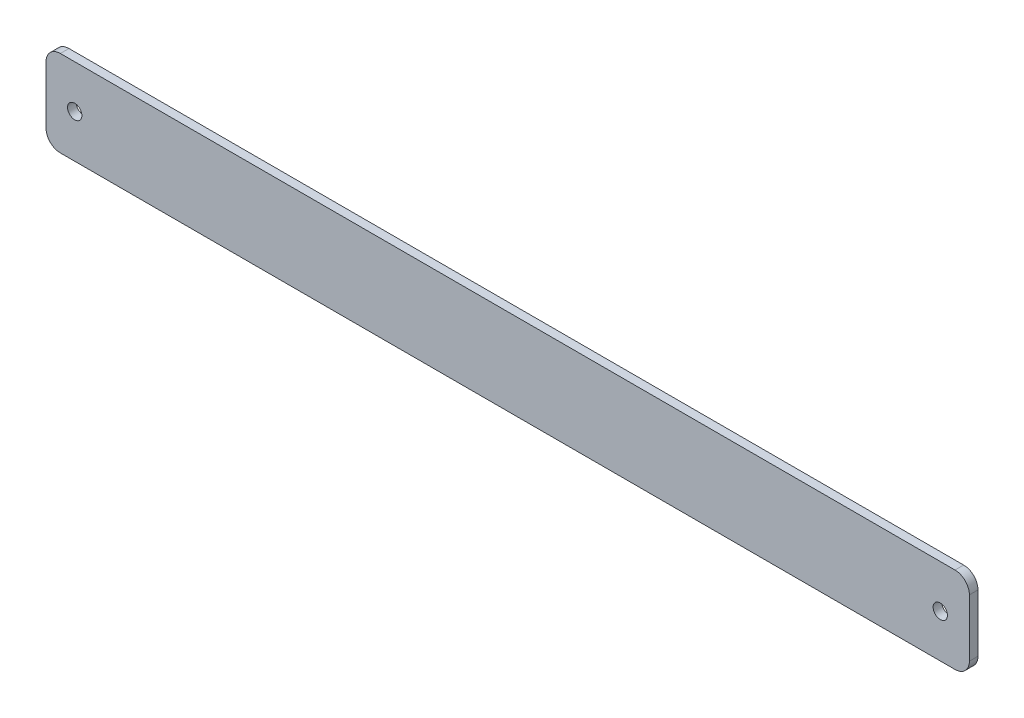
from build123d import *

# Parameters (mm, degrees)
BOSS_EXTRUDE1_DEPTH = 3
SKETCH2_R           = 2.5
CUT_EXTRUDE1_DEPTH  = 4


with BuildPart() as part:
    # Sketch1 → Boss-Extrude1 (new body)
    with BuildSketch(Plane.XY):
        with BuildLine():
            Line((155.75, 15), (0, 15))
            Line((0, 15), (0, 0))
            Line((0, 0), (160.75, 0))
            Line((160.75, 0), (160.75, 10))
            ThreePointArc((160.75, 10), (159.285533906, 13.535533906), (155.75, 15))
        make_face()
        with BuildLine():
            Line((0, 15), (-155.75, 15))
            ThreePointArc((-155.75, 15), (-159.285533906, 13.535533906), (-160.75, 10))
            Line((-160.75, 10), (-160.75, 0))
            Line((-160.75, 0), (0, 0))
            Line((0, 0), (0, 15))
        make_face()
        with BuildLine():
            Line((0, -15), (0, 0))
            Line((0, 0), (-160.75, 0))
            Line((-160.75, 0), (-160.75, -10))
            ThreePointArc((-160.75, -10), (-159.285533906, -13.535533906), (-155.75, -15))
            Line((-155.75, -15), (0, -15))
        make_face()
        with BuildLine():
            Line((160.75, 0), (0, 0))
            Line((0, 0), (0, -15))
            Line((0, -15), (155.75, -15))
            ThreePointArc((155.75, -15), (159.285533906, -13.535533906), (160.75, -10))
            Line((160.75, -10), (160.75, 0))
        make_face()
    extrude(amount=BOSS_EXTRUDE1_DEPTH)

    # Sketch2 → Cut-Extrude1 (cut, through all)
    with BuildSketch(Plane(origin=(0, 0, 0), x_dir=(-1, 0, 0), z_dir=(0, 0, -1))):
        with BuildLine():
            ThreePointArc((-153.120541102, 0), (-150.620541102, -2.5), (-148.120541102, 0))
            Line((-148.120541102, 0), (-153.120541102, 0))
        make_face()
        with BuildLine():
            Line((-153.120541102, 0), (-148.120541102, 0))
            ThreePointArc((-148.120541102, 0), (-150.620541102, 2.5), (-153.120541102, 0))
        make_face()
        with Locations((150.75, 0)):
            Circle(SKETCH2_R)
    extrude(amount=-CUT_EXTRUDE1_DEPTH, mode=Mode.SUBTRACT)


solid = part.part
